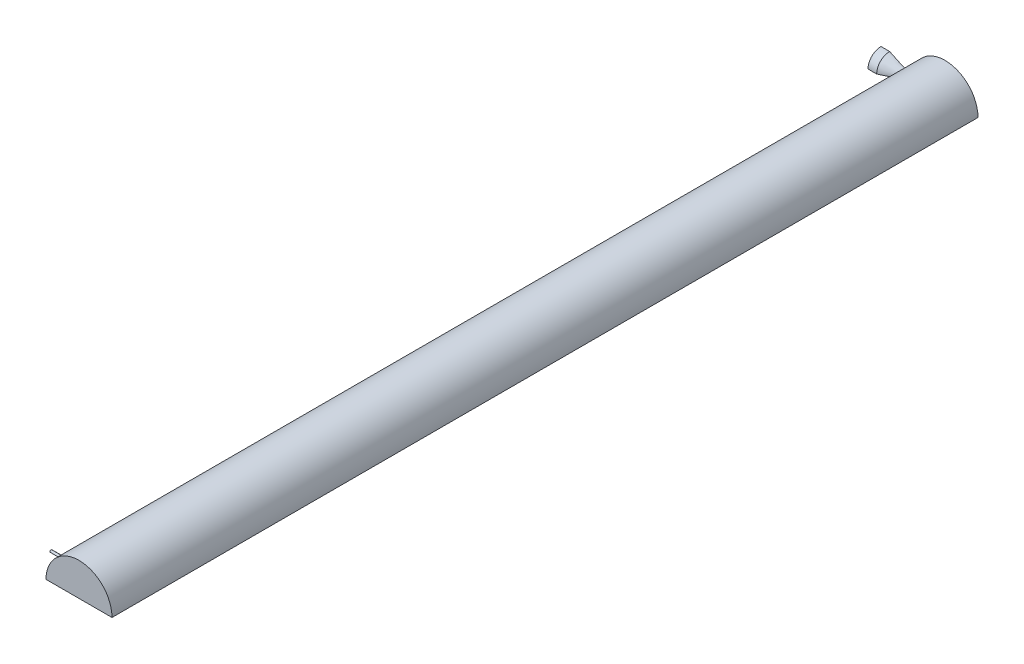
from build123d import *

# Parameters (mm, degrees)
REVOLVE3_ANGLE      = 90
BOSS_EXTRUDE2_DEPTH = 1000
BOSS_EXTRUDE4_DEPTH = 50


with BuildPart() as part:
    # Sketch2 → Revolve3 (revolve)
    with BuildSketch(Plane.XY):
        with BuildLine():
            Line((-0.654182434, 15.02), (-10.654182434, 15.02))
            Line((-10.654182434, 15.02), (-10.654182434, 0))
            Line((-10.654182434, 0), (0, 0))
            Line((0, 0), (25.4, 0))
            Line((25.4, 0), (35.4, 0))
            Line((35.4, 0), (35.4, 4.5))
            Line((35.4, 4.5), (25.4, 4.5))
            add(Edge.make_bspline(
                [(-0.654182434, 15.02), (-0.219836229, 14.810704372), (0.610598489, 14.410982375), (2.74095302, 13.386545583), (4.34709547, 12.619135975), (6.701613478, 11.49599419), (8.606916476, 10.59589253), (10.790885987, 9.570629713), (12.810835282, 8.63757915), (14.944119423, 7.669787097), (16.950761864, 6.79193378), (18.75556814, 6.044207346), (20.238794329, 5.486207444), (21.39416777, 5.103578745), (22.215591012, 4.870934478), (22.897035956, 4.710298297), (23.464492683, 4.605633048), (23.954091395, 4.538072471), (24.354277235, 4.503624983), (24.669284768, 4.488813447), (24.918595629, 4.485402054), (25.124701431, 4.488218611), (25.279381224, 4.493757229), (25.359889237, 4.497669109), (25.4, 4.5)],
                knots=[0.083771138, 0.083771138, 0.083771138, 0.083771138, 0.083771138, 0.152014176, 0.220257214, 0.288500251, 0.356743288, 0.424986327, 0.493229366, 0.561472406, 0.629715448, 0.697958493, 0.757156968, 0.791278497, 0.81934393, 0.841893906, 0.858954658, 0.874282948, 0.887931591, 0.900718778, 0.906405686, 0.912092593, 0.917779499, 0.923466404, 0.923466404, 0.923466404, 0.923466404, 0.923466404], degree=4))
        make_face()
    revolve(axis=Axis((0, 0, 0), (1, 0, 0)), revolution_arc=REVOLVE3_ANGLE)

    # Sketch11 → Boss-Extrude2 (add)
    with BuildSketch(Plane.XY):
        with BuildLine():
            Line((25.133318649, 0), (101.333318649, 0))
            ThreePointArc((101.333318649, 0), (63.233318649, 38.1), (25.133318649, 0))
        make_face()
    extrude(amount=BOSS_EXTRUDE2_DEPTH)

    # Sketch16 → Boss-Extrude4 (add)
    with BuildSketch(Plane(origin=(0, 0, 0), x_dir=(0, 0, -1), z_dir=(1, 0, 0))):
        with BuildLine():
            Line((-967.503760297, 0), (-970.507760297, 0))
            ThreePointArc((-970.507760297, 0), (-969.005760297, 1.502), (-967.503760297, 0))
        make_face()
    extrude(amount=BOSS_EXTRUDE4_DEPTH)


solid = part.part
